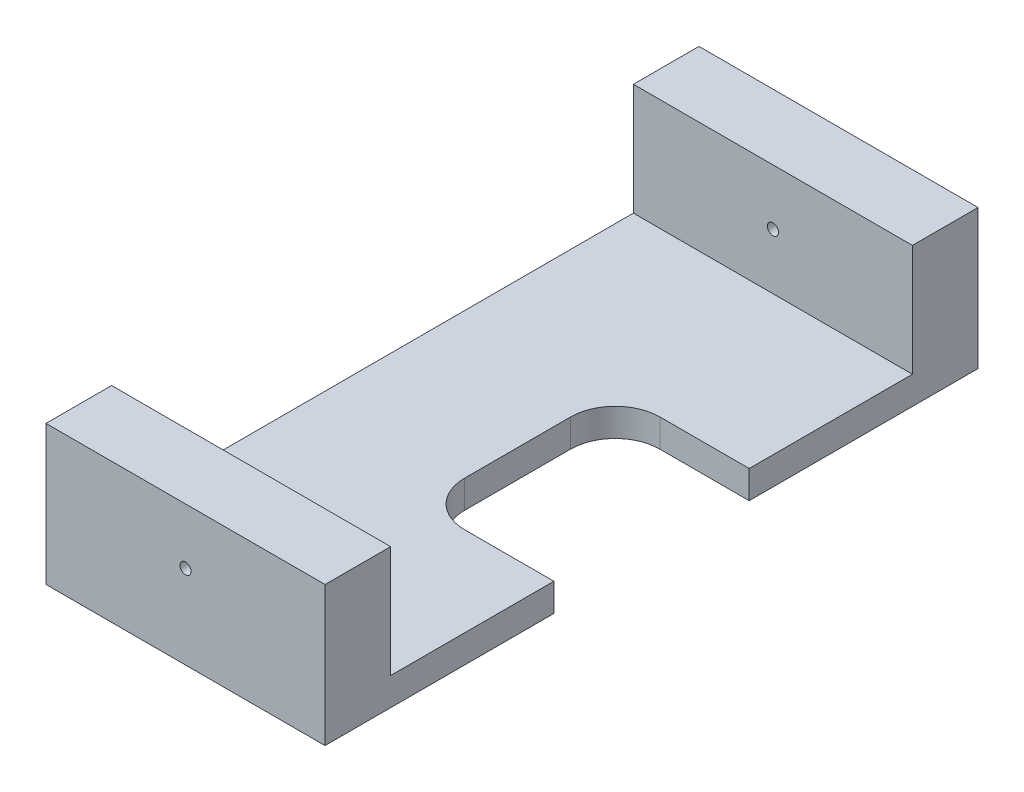
from build123d import *

# Parameters (mm, degrees)
CROQUIS1_W              = 50
CROQUIS1_H              = 117
SALIENTE_EXTRUIR1_DEPTH = 5
CROQUIS2_W              = 50
CROQUIS2_H              = 11.75
SALIENTE_EXTRUIR2_DEPTH = 20
CORTAR_EXTRUIR1_DEPTH   = 10
CROQUIS5_R              = 1
CORTAR_EXTRUIR3_DEPTH   = 118


with BuildPart() as part:
    # Croquis1 → Saliente-Extruir1 (new body)
    with BuildSketch(Plane(origin=(0, 0, 0), x_dir=(1, 0, 0), z_dir=(0, 1, 0))):
        Rectangle(CROQUIS1_W, CROQUIS1_H)
    extrude(amount=SALIENTE_EXTRUIR1_DEPTH)

    # Croquis2 → Saliente-Extruir2 (add)
    with BuildSketch(Plane(origin=(0, 5, 0), x_dir=(1, 0, 0), z_dir=(0, 1, 0))):
        with Locations((0, 52.625)):
            Rectangle(CROQUIS2_W, CROQUIS2_H)
        with Locations((0, -52.625)):
            Rectangle(CROQUIS2_W, CROQUIS2_H)
    extrude(amount=SALIENTE_EXTRUIR2_DEPTH)

    # Croquis3 → Cortar-Extruir1 (cut)
    with BuildSketch(Plane(origin=(0, 5, 0), x_dir=(1, 0, 0), z_dir=(0, 1, 0))):
        with BuildLine():
            Line((25, 17.5), (9, 17.5))
            ThreePointArc((9, 17.5), (3.343145751, 15.156854249), (1, 9.5))
            Line((1, 9.5), (1, -9.5))
            ThreePointArc((1, -9.5), (3.343145751, -15.156854249), (9, -17.5))
            Line((9, -17.5), (25, -17.5))
            Line((25, -17.5), (25, 17.5))
        make_face()
    extrude(amount=-CORTAR_EXTRUIR1_DEPTH, mode=Mode.SUBTRACT)

    # Croquis5 → Cortar-Extruir3 (cut, through all)
    with BuildSketch(Plane(origin=(0, 0, -58.5), x_dir=(-1, 0, 0), z_dir=(0, 0, -1))):
        with Locations((0, 15)):
            Circle(CROQUIS5_R)
    extrude(amount=-CORTAR_EXTRUIR3_DEPTH, mode=Mode.SUBTRACT)


solid = part.part
